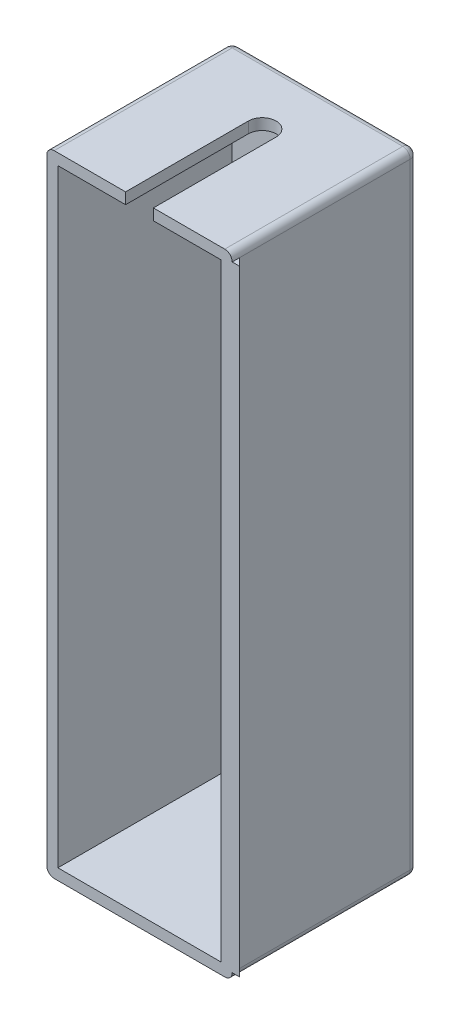
from build123d import *

# Parameters (mm, degrees)
SKETCH2_W           = 50
SKETCH2_H           = 170
BOSS_EXTRUDE1_DEPTH = 50
SKETCH3_W           = 44
SKETCH3_H           = 164
CUT_EXTRUDE1_DEPTH  = 47
FILLET2_R           = 2
SKETCH4_W           = 2
SKETCH4_H           = 166
BOSS_EXTRUDE2_DEPTH = 2
CUT_EXTRUDE2_DEPTH  = 170
CUT_EXTRUDE5_DEPTH  = 10


with BuildPart() as part:
    # Sketch2 → Boss-Extrude1 (new body)
    with BuildSketch(Plane.XY):
        Rectangle(SKETCH2_W, SKETCH2_H)
    extrude(amount=BOSS_EXTRUDE1_DEPTH)

    # Sketch3 → Cut-Extrude1 (cut)
    with BuildSketch(Plane.XY.offset(50)):
        Rectangle(SKETCH3_W, SKETCH3_H)
    extrude(amount=-CUT_EXTRUDE1_DEPTH, mode=Mode.SUBTRACT)

    # Fillet2
    fillet2_edges = [part.edges().sort_by_distance(p)[0] for p in [
        (0, 85, 0),
        (25, 0, 0),
        (0, -85, 0),
        (-25, 0, 0),
        (-25, 85, 25),
        (25, 85, 25),
        (25, -85, 25),
        (-25, -85, 25),
    ]]
    fillet(fillet2_edges, radius=FILLET2_R)

    # Sketch4 → Boss-Extrude2 (add)
    with BuildSketch(Plane(origin=(25, 0, 0), x_dir=(0, 0, -1), z_dir=(1, 0, 0))):
        with Locations((-49, 0)):
            Rectangle(SKETCH4_W, SKETCH4_H)
    extrude(amount=BOSS_EXTRUDE2_DEPTH)

    # Sketch5 → Cut-Extrude2 (cut)
    with BuildSketch(Plane.XZ.offset(83)):
        Polygon((25, 48), (27, 50), (27, 48), align=None)
    extrude(amount=-CUT_EXTRUDE2_DEPTH, mode=Mode.SUBTRACT)

    # Sketch9 → Cut-Extrude5 (cut)
    with BuildSketch(Plane(origin=(0, 85, 0), x_dir=(1, 0, 0), z_dir=(0, 1, 0))):
        with BuildLine():
            Line((3.750279021, -16.895768884), (3.750279021, -50))
            ThreePointArc((3.750279021, -50), (0, -53.750279021), (-3.750279021, -50))
            Line((-3.750279021, -50), (-3.750279021, -16.895768884))
            ThreePointArc((-3.750279021, -16.895768884), (0, -13.145489863), (3.750279021, -16.895768884))
        make_face()
    extrude(amount=-CUT_EXTRUDE5_DEPTH, mode=Mode.SUBTRACT)


solid = part.part
